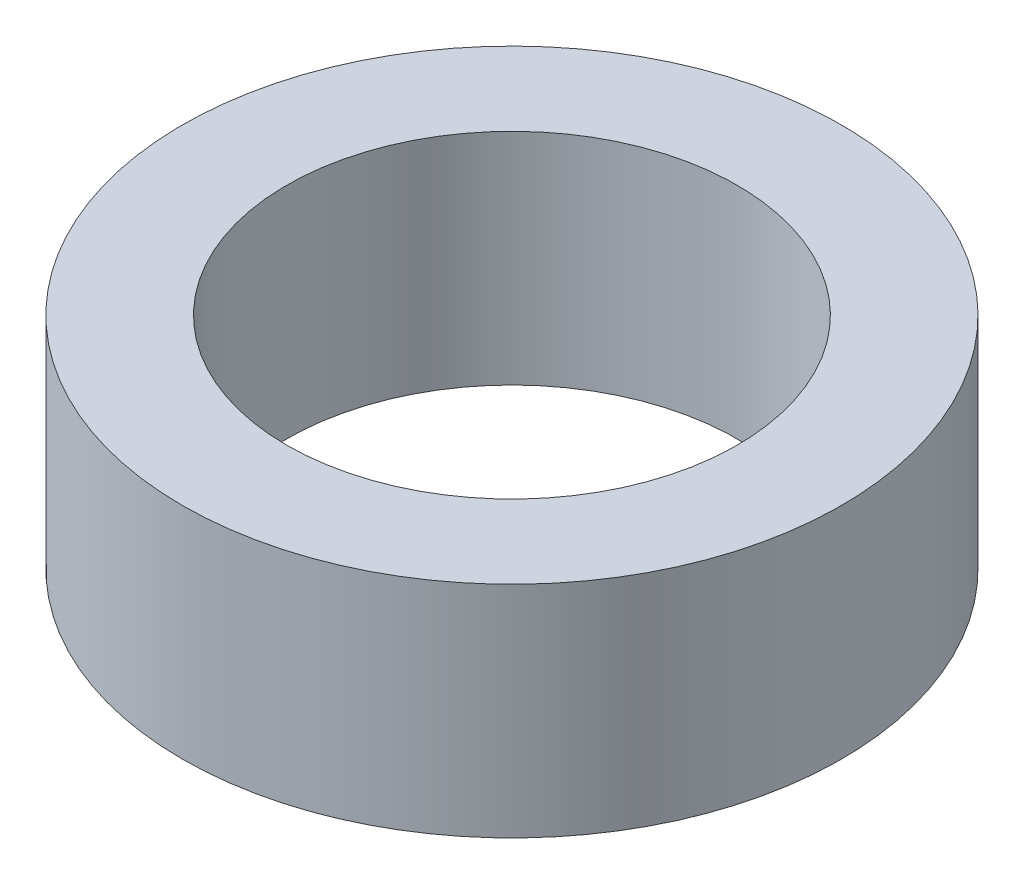
from build123d import *

# Parameters (mm, degrees)
SKETCH_1_R      = 3
SKETCH_1_R_2    = 2.05
EXTRUDE_1_DEPTH = 2


with BuildPart() as part:
    # 草图1 → 凸台-拉伸1 (new body)
    with BuildSketch(Plane(origin=(0, 0, 0), x_dir=(1, 0, 0), z_dir=(0, 1, 0))):
        Circle(SKETCH_1_R)
        Circle(SKETCH_1_R_2, mode=Mode.SUBTRACT)
    extrude(amount=EXTRUDE_1_DEPTH)


solid = part.part
